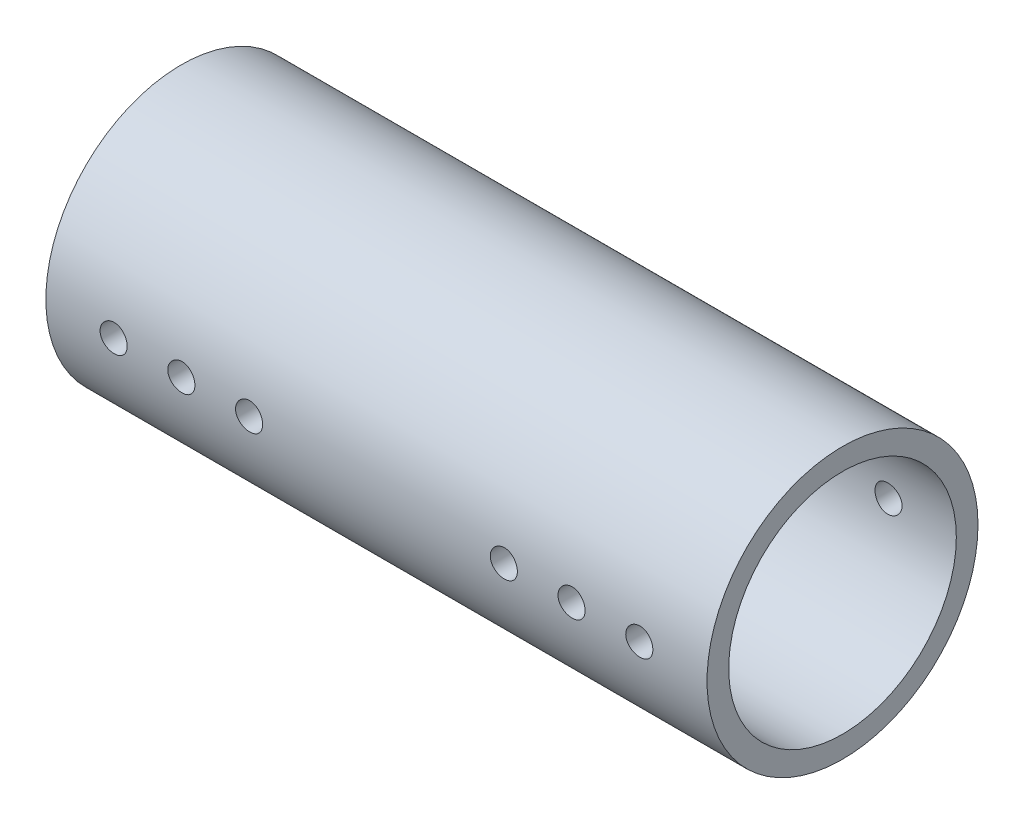
from build123d import *

# Parameters (mm, degrees)
SKETCH_2_R               = 25
SKETCH_2_R_2             = 21
EXTRUDE_2_DEPTH          = 122
CUT_EXTRUDE_2_DEPTH      = 10
CUT_EXTRUDE_2_DEPTH_BACK = 135.197615478
SKETCH_4_R               = 2.5


with BuildPart() as part:
    # Эскиз2 → Бобышка-Вытянуть2 (new body)
    with BuildSketch(Plane(origin=(0, 0, 0), x_dir=(0, 0, -1), z_dir=(1, 0, 0))):
        Circle(SKETCH_2_R)
        Circle(SKETCH_2_R_2, mode=Mode.SUBTRACT)
    extrude(amount=EXTRUDE_2_DEPTH)

    # Эскиз4 → Вырез-Вытянуть2 (cut, two sides: drawn at the far end of the back side and taken through both)
    with BuildSketch(Plane.XY.offset(25).offset(-CUT_EXTRUDE_2_DEPTH_BACK)):
        with Locations((12.5, 0)):
            Circle(SKETCH_4_R)
        with Locations((109.5, 0)):
            Circle(SKETCH_4_R)
        with Locations((25, 0)):
            Circle(SKETCH_4_R)
        with Locations((37.5, 0)):
            Circle(SKETCH_4_R)
        with Locations((97, 0)):
            Circle(SKETCH_4_R)
        with Locations((84.5, 0)):
            Circle(SKETCH_4_R)
    extrude(amount=CUT_EXTRUDE_2_DEPTH + CUT_EXTRUDE_2_DEPTH_BACK, mode=Mode.SUBTRACT)


solid = part.part
